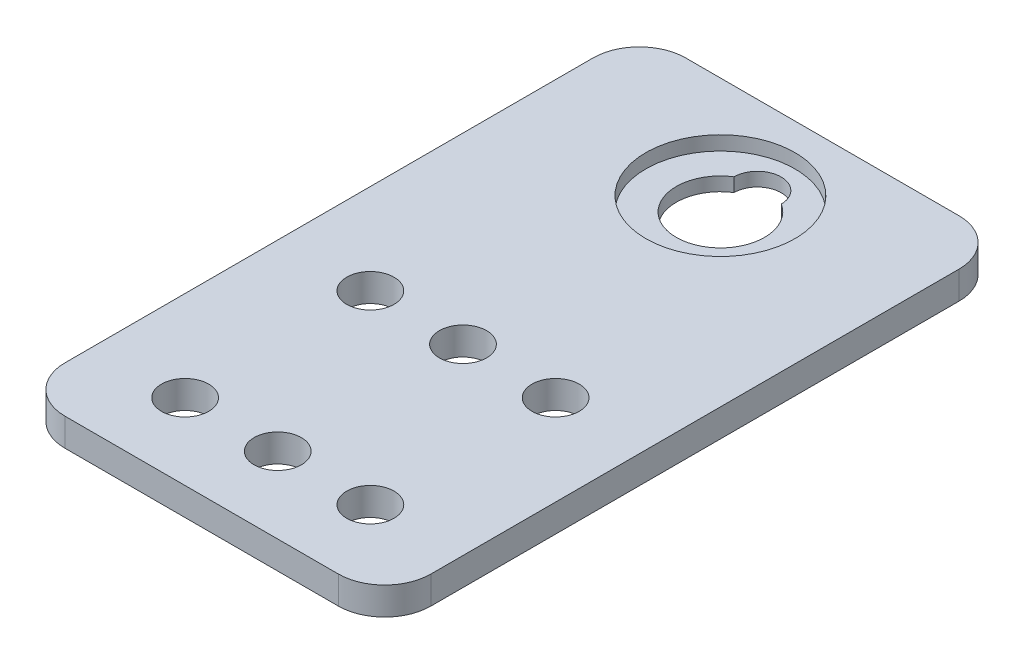
from build123d import *

# Parameters (mm, degrees)
SKETCH1_R                                           = 2.55
BOSS_EXTRUDE1_DEPTH                                 = 3
CBORE_FOR_00_BINDING_HEAD_MACHINE_SCREW_D           = 9.525
CBORE_FOR_00_BINDING_HEAD_MACHINE_SCREW_CBORE_D     = 16.1036
CBORE_FOR_00_BINDING_HEAD_MACHINE_SCREW_CBORE_DEPTH = 1.524


with BuildPart() as part:
    # Sketch1 → Boss-Extrude1 (new body)
    with BuildSketch(Plane(origin=(0, 0, 0), x_dir=(1, 0, 0), z_dir=(0, 1, 0))):
        with BuildLine():
            Line((14.75, -33.5), (-14.75, -33.5))
            ThreePointArc((-14.75, -33.5), (-18.285533906, -32.035533906), (-19.75, -28.5))
            Line((-19.75, -28.5), (-19.75, 28.5))
            ThreePointArc((-19.75, 28.5), (-18.285533906, 32.035533906), (-14.75, 33.5))
            Line((-14.75, 33.5), (14.75, 33.5))
            ThreePointArc((14.75, 33.5), (18.285533906, 32.035533906), (19.75, 28.5))
            Line((19.75, 28.5), (19.75, -28.5))
            ThreePointArc((19.75, -28.5), (18.285533906, -32.035533906), (14.75, -33.5))
        make_face()
        with Locations((0, 26.5)):
            Circle(SKETCH1_R, mode=Mode.SUBTRACT)
        with Locations((10, -25.29)):
            Circle(SKETCH1_R, mode=Mode.SUBTRACT)
        with Locations((10, -5.29)):
            Circle(SKETCH1_R, mode=Mode.SUBTRACT)
        with Locations((0, -25.29)):
            Circle(SKETCH1_R, mode=Mode.SUBTRACT)
        with Locations((0, -5.29)):
            Circle(SKETCH1_R, mode=Mode.SUBTRACT)
        with Locations((-10, -25.29)):
            Circle(SKETCH1_R, mode=Mode.SUBTRACT)
        with Locations((-10, -5.29)):
            Circle(SKETCH1_R, mode=Mode.SUBTRACT)
    extrude(amount=BOSS_EXTRUDE1_DEPTH)

    # CBORE for #00 Binding Head Machine Screw1 (through all)
    with Locations(Plane(origin=(0, 3, 0), x_dir=(1, 0, 0), z_dir=(0, 1, 0))):
        with Locations((0, 22.5)):
            CounterBoreHole(CBORE_FOR_00_BINDING_HEAD_MACHINE_SCREW_D / 2, CBORE_FOR_00_BINDING_HEAD_MACHINE_SCREW_CBORE_D / 2, CBORE_FOR_00_BINDING_HEAD_MACHINE_SCREW_CBORE_DEPTH)


solid = part.part
